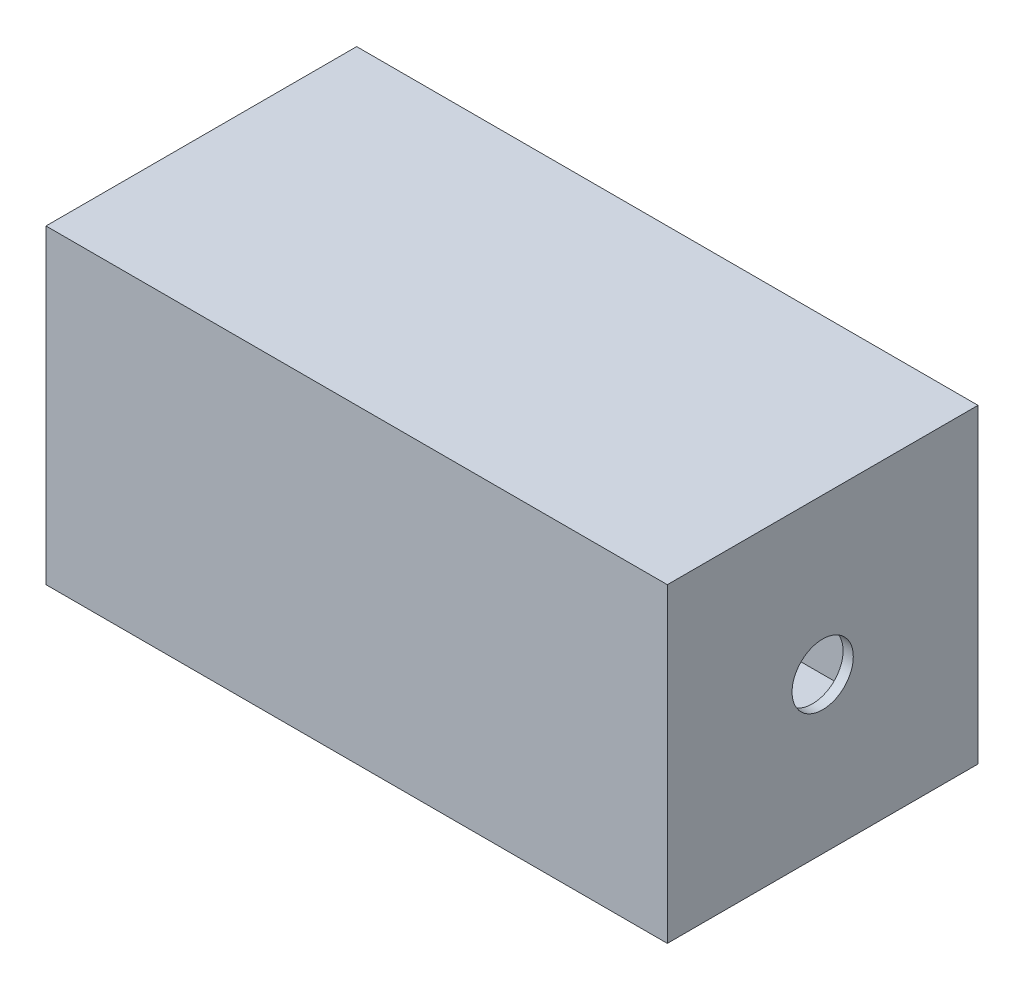
from build123d import *

# Parameters (mm, degrees)
SKETCH1_W           = 610
SKETCH1_H           = 305
BOSS_EXTRUDE1_DEPTH = 305
SHELL1_T            = 10
CUT_EXTRUDE1_REACH  = 612
SKETCH2_R           = 30.075332342


with BuildPart() as part:
    # Sketch1 → Boss-Extrude1 (new body)
    with BuildSketch(Plane(origin=(0, 0, 0), x_dir=(1, 0, 0), z_dir=(0, 1, 0))):
        Rectangle(SKETCH1_W, SKETCH1_H)
    extrude(amount=BOSS_EXTRUDE1_DEPTH)

    # Shell1 (no face opened: a closed hollow body)
    add(offset(amount=-SHELL1_T, mode=Mode.PRIVATE), mode=Mode.SUBTRACT)

    # Sketch2 → Cut-Extrude1 (cut, up to next)
    with BuildSketch(Plane(origin=(305, 0, 0), x_dir=(0, 0, -1), z_dir=(1, 0, 0)), mode=Mode.PRIVATE) as cut_extrude1_sk1:
        with Locations((0, 152.5)):
            Circle(SKETCH2_R)
    cut_extrude1_tool1 = extrude(cut_extrude1_sk1.sketch, amount=-CUT_EXTRUDE1_REACH, mode=Mode.PRIVATE) & part.part
    add(cut_extrude1_tool1.solids().sort_by_distance((305, 152.5, 0))[0], mode=Mode.SUBTRACT)


solid = part.part
